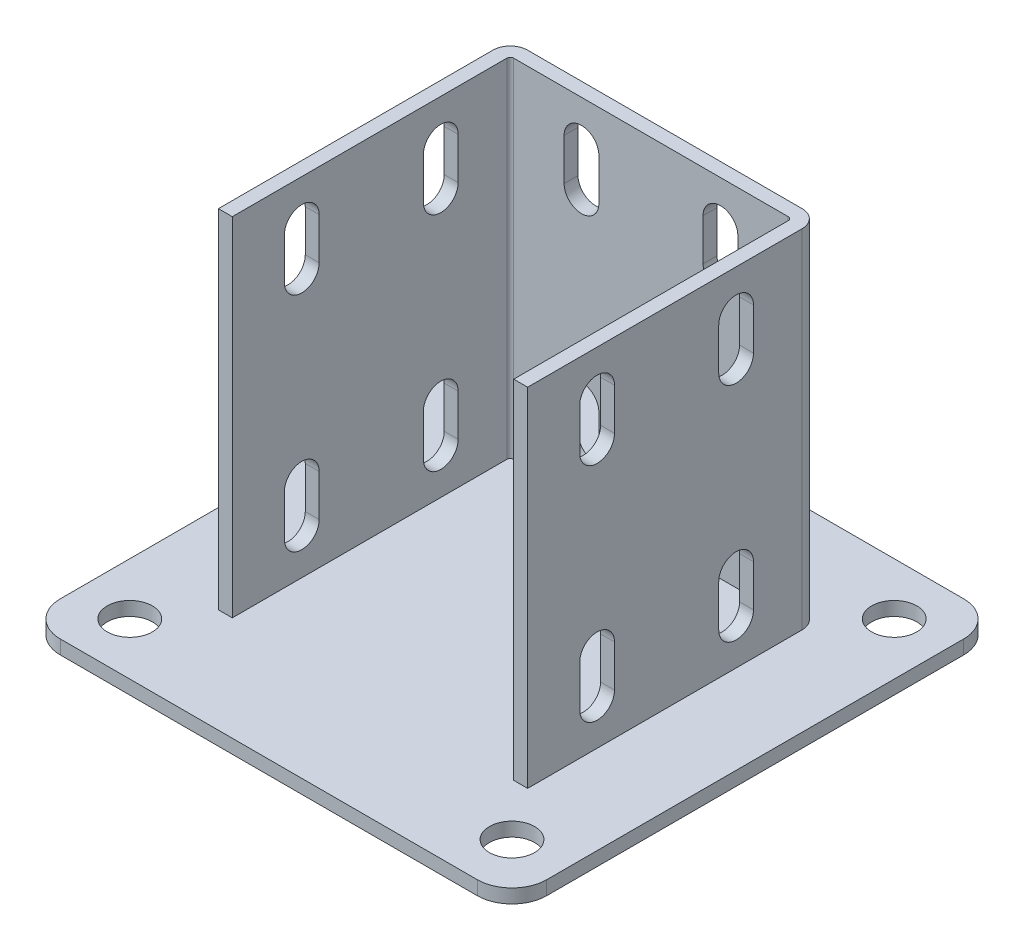
from build123d import *

# Parameters (mm, degrees)
SKETCH_2_W          = 140
SKETCH_2_H          = 140
EXTRUDE_1_DEPTH     = 4
EXTRUDE_1_2_DEPTH   = 100
EXTRUDE_2_DEPTH     = 2
CUT_EXTRUDE_1_DEPTH = 115.5
SKETCH_6_R          = 6.5
CUT_EXTRUDE_2_DEPTH = 5
FILLET_1_R          = 10
CUT_EXTRUDE_3_REACH = 116


with BuildPart() as part:
    # Эскиз2 → Extrude 1 (new body)
    with BuildSketch(Plane(origin=(0, 0, 0), x_dir=(1, 0, 0), z_dir=(0, 1, 0))):
        Rectangle(SKETCH_2_W, SKETCH_2_H)
    extrude(amount=EXTRUDE_1_DEPTH)

    # Эскиз3 → Extrude 1 2 (add)
    with BuildSketch(Plane(origin=(0, 4, 0), x_dir=(1, 0, 0), z_dir=(0, 1, 0))):
        with BuildLine():
            Line((-40.5, -40), (-40.5, 39))
            ThreePointArc((-40.5, 39), (-40.207106781, 39.707106781), (-39.5, 40))
            Line((-39.5, 40), (39.5, 40))
            ThreePointArc((39.5, 40), (40.207106781, 39.707106781), (40.5, 39))
            Line((40.5, 39), (40.5, -40))
            Line((40.5, -40), (44.5, -40))
            Line((44.5, -40), (44.5, 39))
            ThreePointArc((44.5, 39), (43.035533906, 42.535533906), (39.5, 44))
            Line((39.5, 44), (-39.5, 44))
            ThreePointArc((-39.5, 44), (-43.035533906, 42.535533906), (-44.5, 39))
            Line((-44.5, 39), (-44.5, -40))
            Line((-44.5, -40), (-40.5, -40))
        make_face()
    extrude(amount=EXTRUDE_1_2_DEPTH)

    # Эскиз4 → Бобышка-Вытянуть2 (add, symmetric)
    with BuildSketch(Plane(origin=(0, 0, 0), x_dir=(0, 0, -1), z_dir=(1, 0, 0))):
        Polygon((44, 40.373066959), (65, 4), (44, 4), align=None)
    extrude(amount=EXTRUDE_2_DEPTH, both=True)

    # Эскиз5 → Вырез-Вытянуть1 (cut, through all)
    with BuildSketch(Plane(origin=(44.5, 0, 0), x_dir=(0, 0, -1), z_dir=(1, 0, 0))):
        with BuildLine():
            Line((-15, 92), (-15, 80))
            ThreePointArc((-15, 80), (-20, 75), (-25, 80))
            Line((-25, 80), (-25, 92))
            ThreePointArc((-25, 92), (-20, 97), (-15, 92))
        make_face()
        with BuildLine():
            Line((-15, 28), (-15, 16))
            ThreePointArc((-15, 16), (-20, 11), (-25, 16))
            Line((-25, 16), (-25, 28))
            ThreePointArc((-25, 28), (-20, 33), (-15, 28))
        make_face()
        with BuildLine():
            Line((15, 92), (15, 80))
            ThreePointArc((15, 80), (20, 75), (25, 80))
            Line((25, 80), (25, 92))
            ThreePointArc((25, 92), (20, 97), (15, 92))
        make_face()
        with BuildLine():
            Line((15, 28), (15, 16))
            ThreePointArc((15, 16), (20, 11), (25, 16))
            Line((25, 16), (25, 28))
            ThreePointArc((25, 28), (20, 33), (15, 28))
        make_face()
    extrude(amount=-CUT_EXTRUDE_1_DEPTH, mode=Mode.SUBTRACT)

    # Эскиз6 → Вырез-Вытянуть2 (cut, through all)
    with BuildSketch(Plane(origin=(0, 4, 0), x_dir=(1, 0, 0), z_dir=(0, 1, 0))):
        with Locations(Location((-55, 55, 0), (0, 0, 270))):  # turned: the seam where the file's is
            Circle(SKETCH_6_R)
        with Locations(Location((-55, -55, 0), (0, 0, 270))):  # turned: the seam where the file's is
            Circle(SKETCH_6_R)
        with Locations(Location((55, 55, 0), (0, 0, 270))):  # turned: the seam where the file's is
            Circle(SKETCH_6_R)
        with Locations(Location((55, -55, 0), (0, 0, 270))):  # turned: the seam where the file's is
            Circle(SKETCH_6_R)
    extrude(amount=-CUT_EXTRUDE_2_DEPTH, mode=Mode.SUBTRACT)

    # Скругление1
    fillet_1_edges = [part.edges().sort_by_distance(p)[0] for p in [
        (70, 2, 70),
        (-70, 2, 70),
        (-70, 2, -70),
        (70, 2, -70),
    ]]
    fillet(fillet_1_edges, radius=FILLET_1_R)

    # Эскиз8 → Вырез-Вытянуть3 (cut, up to next)
    with BuildSketch(Plane(origin=(0, 0, -44), x_dir=(-1, 0, 0), z_dir=(0, 0, -1)), mode=Mode.PRIVATE) as cut_extrude_3_sk1:
        with BuildLine():
            Line((-15, 92), (-15, 80))
            ThreePointArc((-15, 80), (-20, 75), (-25, 80))
            Line((-25, 80), (-25, 92))
            ThreePointArc((-25, 92), (-20, 97), (-15, 92))
        make_face()
    cut_extrude_3_tool1 = extrude(cut_extrude_3_sk1.sketch, amount=-CUT_EXTRUDE_3_REACH, mode=Mode.PRIVATE) & part.part
    add(cut_extrude_3_tool1.solids().sort_by_distance((20, 86, -44))[0], mode=Mode.SUBTRACT)
    # Эскиз8 → Вырез-Вытянуть3 (cut, up to next)
    with BuildSketch(Plane(origin=(0, 0, -44), x_dir=(-1, 0, 0), z_dir=(0, 0, -1)), mode=Mode.PRIVATE) as cut_extrude_3_sk2:
        with BuildLine():
            Line((-15, 28), (-15, 16))
            ThreePointArc((-15, 16), (-20, 11), (-25, 16))
            Line((-25, 16), (-25, 28))
            ThreePointArc((-25, 28), (-20, 33), (-15, 28))
        make_face()
    cut_extrude_3_tool2 = extrude(cut_extrude_3_sk2.sketch, amount=-CUT_EXTRUDE_3_REACH, mode=Mode.PRIVATE) & part.part
    add(cut_extrude_3_tool2.solids().sort_by_distance((20, 22, -44))[0], mode=Mode.SUBTRACT)
    # Эскиз8 → Вырез-Вытянуть3 (cut, up to next)
    with BuildSketch(Plane(origin=(0, 0, -44), x_dir=(-1, 0, 0), z_dir=(0, 0, -1)), mode=Mode.PRIVATE) as cut_extrude_3_sk3:
        with BuildLine():
            Line((15, 92), (15, 80))
            ThreePointArc((15, 80), (20, 75), (25, 80))
            Line((25, 80), (25, 92))
            ThreePointArc((25, 92), (20, 97), (15, 92))
        make_face()
    cut_extrude_3_tool3 = extrude(cut_extrude_3_sk3.sketch, amount=-CUT_EXTRUDE_3_REACH, mode=Mode.PRIVATE) & part.part
    add(cut_extrude_3_tool3.solids().sort_by_distance((-20, 86, -44))[0], mode=Mode.SUBTRACT)
    # Эскиз8 → Вырез-Вытянуть3 (cut, up to next)
    with BuildSketch(Plane(origin=(0, 0, -44), x_dir=(-1, 0, 0), z_dir=(0, 0, -1)), mode=Mode.PRIVATE) as cut_extrude_3_sk4:
        with BuildLine():
            Line((15, 28), (15, 16))
            ThreePointArc((15, 16), (20, 11), (25, 16))
            Line((25, 16), (25, 28))
            ThreePointArc((25, 28), (20, 33), (15, 28))
        make_face()
    cut_extrude_3_tool4 = extrude(cut_extrude_3_sk4.sketch, amount=-CUT_EXTRUDE_3_REACH, mode=Mode.PRIVATE) & part.part
    add(cut_extrude_3_tool4.solids().sort_by_distance((-20, 22, -44))[0], mode=Mode.SUBTRACT)


solid = part.part
